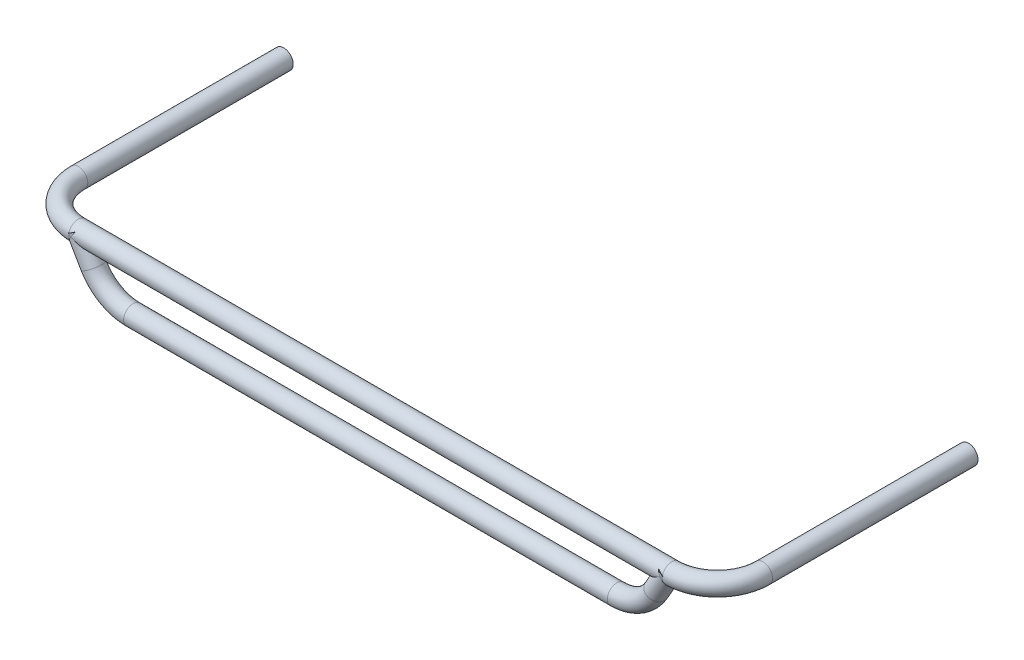
from build123d import *

# Parameters (mm, degrees)
SKETCH2_R           = 8.35
SKETCH4_R           = 8.35
BOSS_EXTRUDE2_DEPTH = 13
BOSS_EXTRUDE3_DEPTH = 13
SKETCH7_R           = 8.35
BOSS_EXTRUDE4_DEPTH = 80
SKETCH8_R           = 8.35
BOSS_EXTRUDE5_DEPTH = 80


with BuildPart() as part:
    # Sweep1: sweep along a path in Sketch1
    with BuildLine(Plane(origin=(0, 0, 0), x_dir=(1, 0, 0), z_dir=(0, 1, 0))) as sweep1_path:
        Line((-300, 0), (-300, -100))
        ThreePointArc((-300, -100), (-288.284271247, -128.284271247), (-260, -140))
        Line((-260, -140), (260, -140))
        ThreePointArc((260, -140), (288.284271247, -128.284271247), (300, -100))
        Line((300, -100), (300, 0))
    # Sketch2 → Sweep1 (sweep)
    with BuildSketch(Plane.XY):
        with Locations((300, 0)):
            Circle(SKETCH2_R)
    sweep(path=sweep1_path.line)

    # Sweep2: sweep along a path in Sketch3
    with BuildLine(Plane.XY.offset(140)) as sweep2_path:
        Line((-252.853261493, -9.077244013), (-246.547005384, -20))
        ThreePointArc((-246.547005384, -20), (-231.905989232, -34.641016151), (-211.905989232, -40))
        Line((-211.905989232, -40), (211.905989232, -40))
        ThreePointArc((211.905989232, -40), (231.905989232, -34.641016151), (246.547005384, -20))
        Line((246.547005384, -20), (252.853261493, -9.077244013))
    # Sketch4 → Sweep2 (sweep)
    with BuildSketch(Plane(origin=(-252.853261493, -9.077244013, 140), x_dir=(0.866025404, 0.5, 0), z_dir=(-0.5, 0.866025404, 0))):
        Circle(SKETCH4_R)
    sweep(path=sweep2_path.line)

    # Sketch5 → Boss-Extrude2 (add)
    with BuildSketch(Plane(origin=(-59.282753417, 102.680740932, 0), x_dir=(0.866025404, 0.5, 0), z_dir=(-0.5, 0.866025404, 0))):
        with BuildLine():
            ThreePointArc((-217.464473881, -134.246575276), (-231.865969889, -140), (-217.464473881, -145.753424724))
            add(Edge.make_bspline(
                [(-217.464473881, -134.246575276), (-228.404544239, -140), (-217.464473881, -145.753424724)],
                knots=[2.381438875, 2.381438875, 2.381438875, 3.901746432, 3.901746432, 3.901746432], degree=2, weights=[1, 0.724730061, 1]))
        make_face()
    extrude(amount=BOSS_EXTRUDE2_DEPTH)

    # Sketch6 → Boss-Extrude3 (add)
    with BuildSketch(Plane(origin=(59.282753417, 102.680740932, 0), x_dir=(0.866025404, -0.5, 0), z_dir=(0.5, 0.866025404, 0))):
        with BuildLine():
            ThreePointArc((217.464473881, -145.753424724), (231.865969889, -140), (217.464473881, -134.246575276))
            add(Edge.make_bspline(
                [(217.464473881, -145.753424724), (228.404544239, -140), (217.464473881, -134.246575276)],
                knots=[5.523031529, 5.523031529, 5.523031529, 7.043339086, 7.043339086, 7.043339086], degree=2, weights=[1, 0.724730061, 1]))
        make_face()
    extrude(amount=BOSS_EXTRUDE3_DEPTH)

    # Sketch7 → Boss-Extrude4 (add)
    with BuildSketch(Plane(origin=(0, 0, 0), x_dir=(-1, 0, 0), z_dir=(0, 0, -1))):
        with Locations((-300, 0)):
            Circle(SKETCH7_R)
    extrude(amount=BOSS_EXTRUDE4_DEPTH)

    # Sketch8 → Boss-Extrude5 (add)
    with BuildSketch(Plane(origin=(0, 0, 0), x_dir=(-1, 0, 0), z_dir=(0, 0, -1))):
        with Locations((300, 0)):
            Circle(SKETCH8_R)
    extrude(amount=BOSS_EXTRUDE5_DEPTH)


solid = part.part
